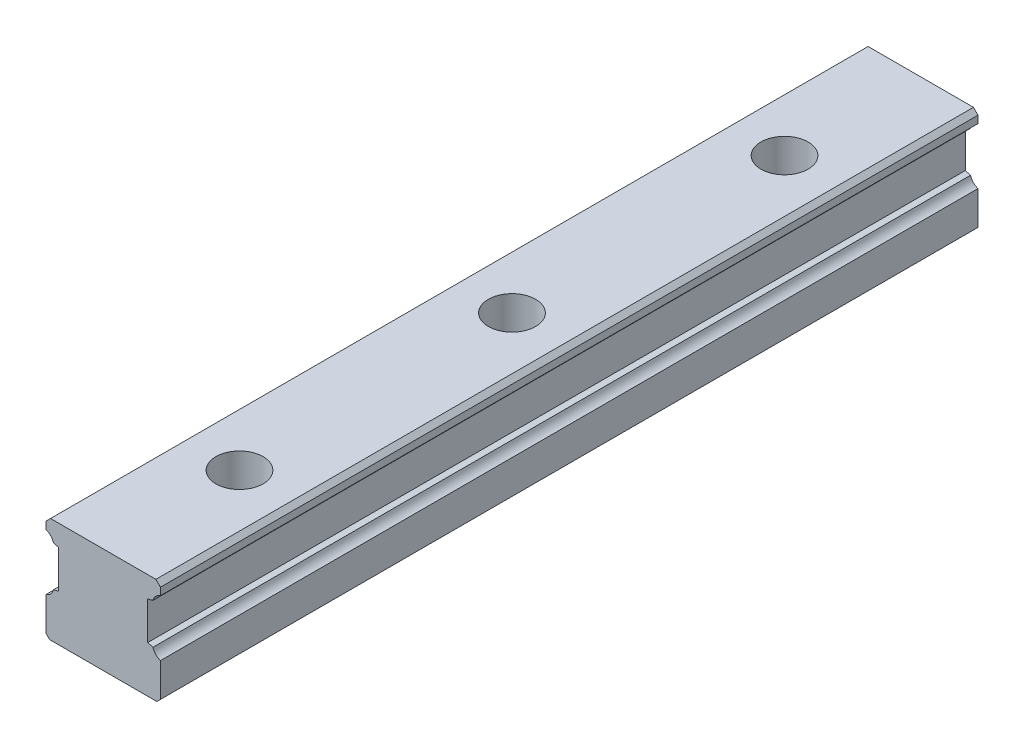
from build123d import *

# Parameters (mm, degrees)
RESSALTO_EXTRUS_O1_DEPTH                             = 450
REBAIXO_PARA_PARAFUSO_DE_CABE_A_SEXTAVAD_D           = 18
REBAIXO_PARA_PARAFUSO_DE_CABE_A_SEXTAVAD_DEPTH       = 58
REBAIXO_PARA_PARAFUSO_DE_CABE_A_SEXTAVAD_CBORE_D     = 26
REBAIXO_PARA_PARAFUSO_DE_CABE_A_SEXTAVAD_CBORE_DEPTH = 25
CHANFRO1_SIZE2                                       = 2.500287455
CHANFRO1_SIZE                                        = 2.500257245
CHANFRO2_SIZE2                                       = 2.500423779
CHANFRO2_SIZE                                        = 2.500287455
CHANFRO3_SIZE                                        = 2


with BuildPart() as part:
    # Esboço1 → Ressalto-extrusão1 (new body)
    with BuildSketch(Plane.XY):
        with BuildLine():
            Line((-31.5, 20.527298986), (-31.5, 0))
            Line((-31.5, 0), (31.5, 0))
            Line((31.5, 0), (31.5, 20.527298986))
            ThreePointArc((31.5, 20.527298986), (28.900076881, 22.150342104), (27.397266061, 24.82156445))
            Line((27.397266061, 24.82156445), (24.5, 25.597882749))
            Line((24.5, 25.597882749), (24.5, 46.397686197))
            Line((24.5, 46.397686197), (27.397119712, 47.17387922))
            ThreePointArc((27.397119712, 47.17387922), (28.898613337, 49.848990738), (31.5, 51.474872705))
            Line((31.5, 51.474872705), (31.5, 58))
            Line((31.5, 58), (-31.5, 58))
            Line((-31.5, 58), (-31.5, 51.474872705))
            ThreePointArc((-31.5, 51.474872705), (-28.899411057, 49.849685923), (-27.397802135, 47.175837466))
            Line((-27.397802135, 47.175837466), (-24.5, 46.399706372))
            Line((-24.5, 46.399706372), (-24.5, 25.596973237))
            Line((-24.5, 25.596973237), (-27.397939574, 24.823365186))
            ThreePointArc((-27.397939574, 24.823365186), (-28.900095464, 22.151244343), (-31.5, 20.527298986))
        make_face()
    extrude(amount=RESSALTO_EXTRUS_O1_DEPTH)

    # Rebaixo para parafuso de cabeça sextavada de M161
    with Locations(Plane(origin=(0, 58, 0), x_dir=(1, 0, 0), z_dir=(0, 1, 0))):
        with Locations((0, -75), (0, -1425), (0, -1275), (0, -1125), (0, -975), (0, -825), (0, -675), (0, -525), (0, -375), (0, -225)):
            CounterBoreHole(REBAIXO_PARA_PARAFUSO_DE_CABE_A_SEXTAVAD_D / 2, REBAIXO_PARA_PARAFUSO_DE_CABE_A_SEXTAVAD_CBORE_D / 2, REBAIXO_PARA_PARAFUSO_DE_CABE_A_SEXTAVAD_CBORE_DEPTH, depth=REBAIXO_PARA_PARAFUSO_DE_CABE_A_SEXTAVAD_DEPTH)

    # Chanfro1
    chanfro1_edges = [part.edges().sort_by_distance(p)[0] for p in [
        (-31.5, 58, 225),
    ]]
    chamfer(chanfro1_edges, length=CHANFRO1_SIZE, length2=CHANFRO1_SIZE2)

    # Chanfro2
    chanfro2_edges = [part.edges().sort_by_distance(p)[0] for p in [
        (31.5, 58, 225),
    ]]
    chamfer(chanfro2_edges, length=CHANFRO2_SIZE, length2=CHANFRO2_SIZE2)

    # Chanfro3
    chanfro3_edges = [part.edges().sort_by_distance(p)[0] for p in [
        (31.5, 0, 225),
        (-31.5, 0, 225),
    ]]
    chamfer(chanfro3_edges, length=CHANFRO3_SIZE)


solid = part.part
